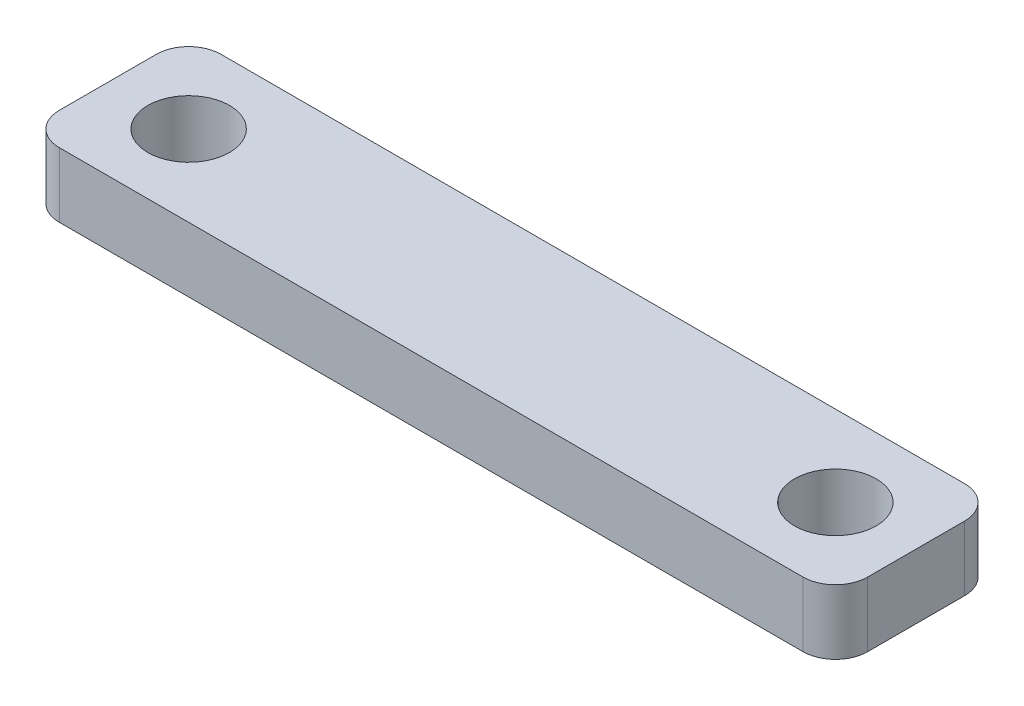
from build123d import *

# Parameters (mm, degrees)
SKETCH_1_W      = 50
SKETCH_1_H      = 10
SKETCH_1_R      = 2.525
EXTRUDE_1_DEPTH = 4
FILLET_1_R      = 2


with BuildPart() as part:
    # 草图1 → 凸台-拉伸1 (new body)
    with BuildSketch(Plane(origin=(0, 0, 0), x_dir=(1, 0, 0), z_dir=(0, 1, 0))):
        with Locations((-20, 0)):
            Rectangle(SKETCH_1_W, SKETCH_1_H)
        Circle(SKETCH_1_R, mode=Mode.SUBTRACT)
        with Locations((-40, 0)):
            Circle(SKETCH_1_R, mode=Mode.SUBTRACT)
    extrude(amount=EXTRUDE_1_DEPTH)

    # 圆角1
    fillet_1_edges = [part.edges().sort_by_distance(p)[0] for p in [
        (-45, 2, -5),
        (5, 2, -5),
        (5, 2, 5),
        (-45, 2, 5),
    ]]
    fillet(fillet_1_edges, radius=FILLET_1_R)


solid = part.part
